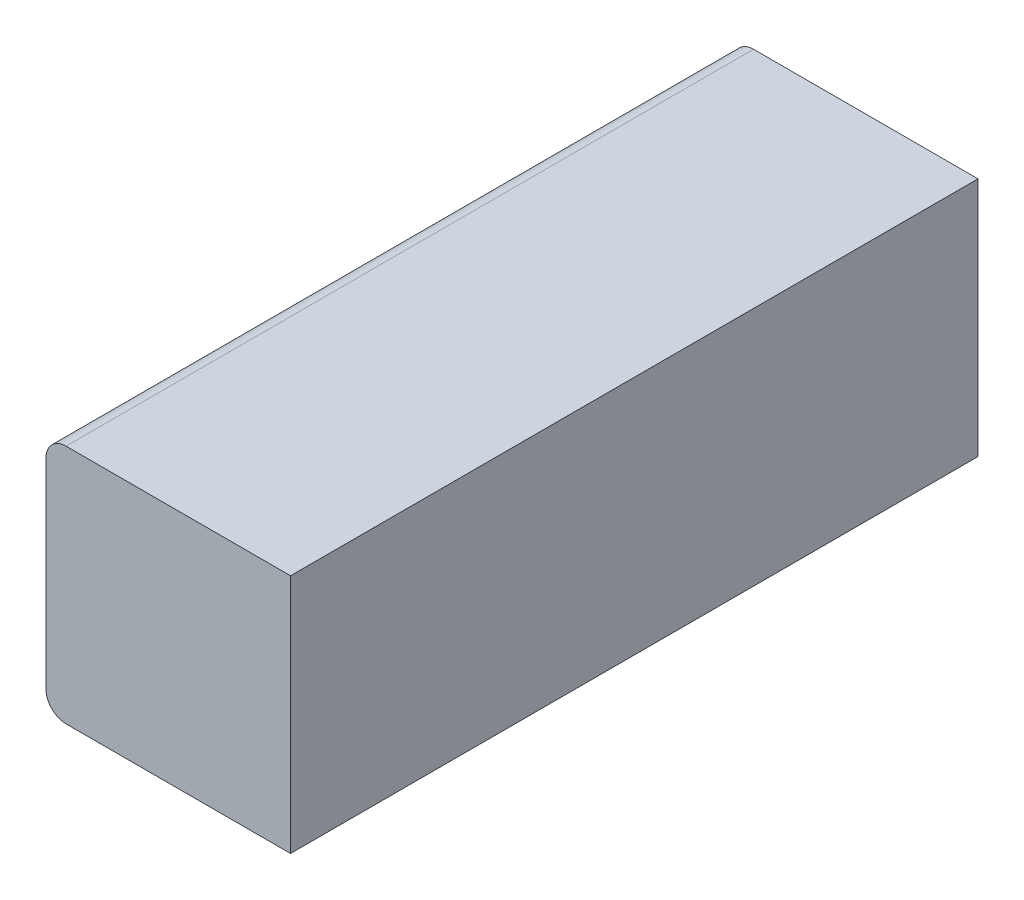
from build123d import *

# Parameters (mm, degrees)
ESBO_O1_W                = 610
ESBO_O1_H                = 600
RESSALTO_EXTRUS_O1_DEPTH = 1715
FILETE1_R                = 50


with BuildPart() as part:
    # Esboço1 → Ressalto-extrusão1 (new body)
    with BuildSketch(Plane.XY):
        with Locations((305, 300)):
            Rectangle(ESBO_O1_W, ESBO_O1_H)
    extrude(amount=RESSALTO_EXTRUS_O1_DEPTH)

    # Filete1
    filete1_edges = [part.edges().sort_by_distance(p)[0] for p in [
        (0, 600, 857.5),
        (0, 0, 857.5),
    ]]
    fillet(filete1_edges, radius=FILETE1_R)


solid = part.part
